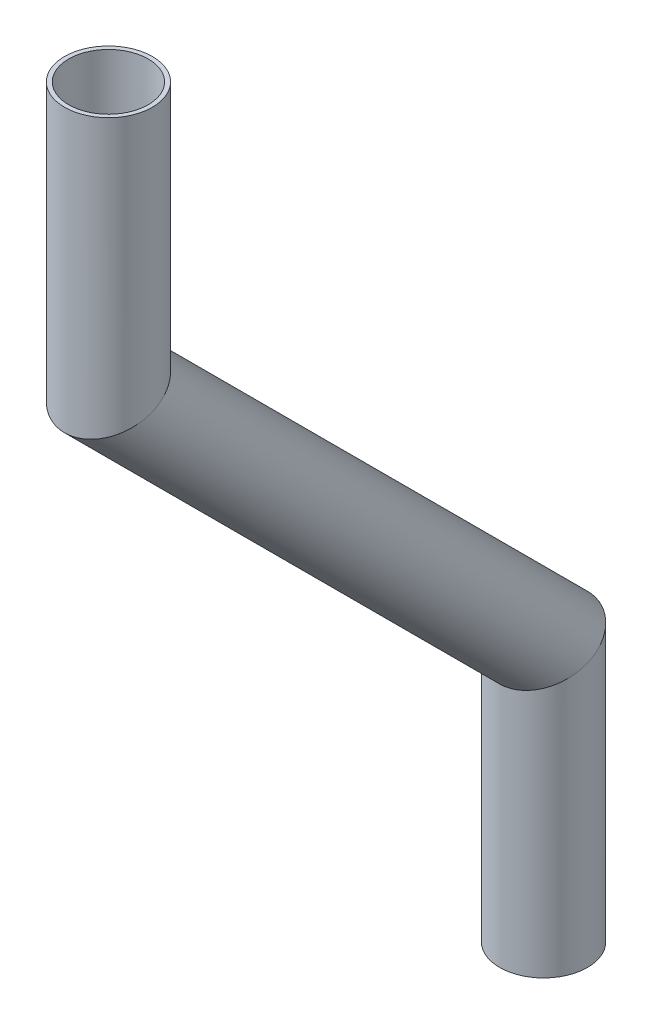
from build123d import *

# Parameters (mm, degrees)
SKETCH11_R                = 6.35
SKETCH11_R_2              = 5.7404
PIPE_0_5_SCH_40_1_DEPTH   = 42.819743879
SKETCH11_ON_SEGMENT_2_R   = 6.35
SKETCH11_ON_SEGMENT_2_R_2 = 5.7404
PIPE_0_5_SCH_40_1_2_DEPTH = 98.339487758
SKETCH11_ON_SEGMENT_3_R   = 6.35
SKETCH11_ON_SEGMENT_3_R_2 = 5.7404
PIPE_0_5_SCH_40_1_3_DEPTH = 42.819743879


with BuildPart() as part:
    # Sketch11 → Pipe 0.5 SCH 40(1) (new body)
    with BuildSketch(Plane(origin=(0, -50.516236303, 307.598264834), x_dir=(0, 0, -1), z_dir=(0, -1, 0))):
        Circle(SKETCH11_R)
        Circle(SKETCH11_R_2, mode=Mode.SUBTRACT)
    extrude(amount=PIPE_0_5_SCH_40_1_DEPTH)

    # Pipe 0.5 SCH 40(1) mitre 1
    split(bisect_by=Plane(origin=(0, -88.616236303, 307.598264834), x_dir=(-1, 0, 0), z_dir=(0, 0.923879533, 0.382683432)), keep=Keep.TOP)


with BuildPart() as body_2:
    # Sketch11 on segment 2 (carried to segment 2) → Pipe 0.5 SCH 40_1 2 (new body)
    with BuildSketch(Plane(origin=(0, -85.278873401, 310.935627736), x_dir=(0, 0.707106781, -0.707106781), z_dir=(0, -0.707106781, -0.707106781))):
        Circle(SKETCH11_ON_SEGMENT_2_R)
        Circle(SKETCH11_ON_SEGMENT_2_R_2, mode=Mode.SUBTRACT)
    extrude(amount=PIPE_0_5_SCH_40_1_2_DEPTH)

    # Pipe 0.5 SCH 40_1 2 mitre 1
    split(bisect_by=Plane(origin=(0, -88.616236303, 307.598264834), x_dir=(1, 0, 0), z_dir=(0, -0.923879533, -0.382683432)), keep=Keep.TOP)

    # Pipe 0.5 SCH 40_1 2 mitre 2
    split(bisect_by=Plane(origin=(0, -151.47802915, 244.736471986), x_dir=(-1, 0, 0), z_dir=(0, 0.923879533, 0.382683432)), keep=Keep.TOP)


with BuildPart() as body_3:
    # Sketch11 on segment 3 (carried to segment 3) → Pipe 0.5 SCH 40_1 3 (new body)
    with BuildSketch(Plane(origin=(0, -146.758285271, 244.736471986), x_dir=(0, 0, -1), z_dir=(0, -1, 0))):
        Circle(SKETCH11_ON_SEGMENT_3_R)
        Circle(SKETCH11_ON_SEGMENT_3_R_2, mode=Mode.SUBTRACT)
    extrude(amount=PIPE_0_5_SCH_40_1_3_DEPTH)

    # Pipe 0.5 SCH 40_1 3 mitre 1
    split(bisect_by=Plane(origin=(0, -151.47802915, 244.736471986), x_dir=(1, 0, 0), z_dir=(0, -0.923879533, -0.382683432)), keep=Keep.TOP)


solid = Compound([part.part, body_2.part, body_3.part])
